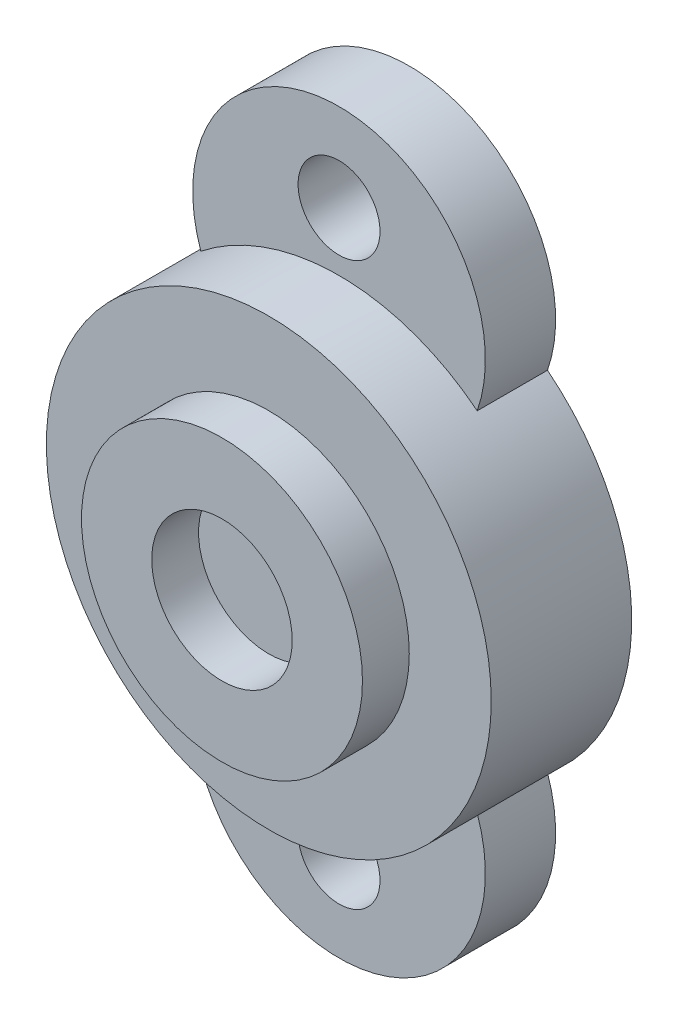
from build123d import *

# Parameters (mm, degrees)
SKETCH1_R      = 12
SKETCH1_R_2    = 3.5
EXTRUDE1_DEPTH = 6
SKETCH1_3_R    = 12
SKETCH1_3_R_2  = 6
EXTRUDE2_DEPTH = 16
SKETCH2_R      = 19
EXTRUDE3_DEPTH = 6


with BuildPart() as part:
    # Sketch1 → Extrude1 (new body)
    with BuildSketch(Plane.XY):
        with BuildLine():
            ThreePointArc((11.804353201, 14.888157895), (0, 31.5), (-11.804353201, 14.888157895))
            ThreePointArc((-11.804353201, 14.888157895), (-19, 0), (-11.804353201, -14.888157895))
            ThreePointArc((-11.804353201, -14.888157895), (0, -31.5), (11.804353201, -14.888157895))
            ThreePointArc((11.804353201, -14.888157895), (19, 0), (11.804353201, 14.888157895))
        make_face()
        Circle(SKETCH1_R, mode=Mode.SUBTRACT)
        with Locations((0, 24)):
            Circle(SKETCH1_R_2, mode=Mode.SUBTRACT)
        with Locations((0, -24)):
            Circle(SKETCH1_R_2, mode=Mode.SUBTRACT)
    extrude(amount=EXTRUDE1_DEPTH)

    # Sketch1_3 → Extrude2 (add)
    with BuildSketch(Plane.XY):
        Circle(SKETCH1_3_R)
        Circle(SKETCH1_3_R_2, mode=Mode.SUBTRACT)
    extrude(amount=EXTRUDE2_DEPTH)

    # Sketch2 → Extrude3 (add)
    with BuildSketch(Plane.XY.offset(6)):
        Circle(SKETCH2_R)
    extrude(amount=EXTRUDE3_DEPTH)


solid = part.part
